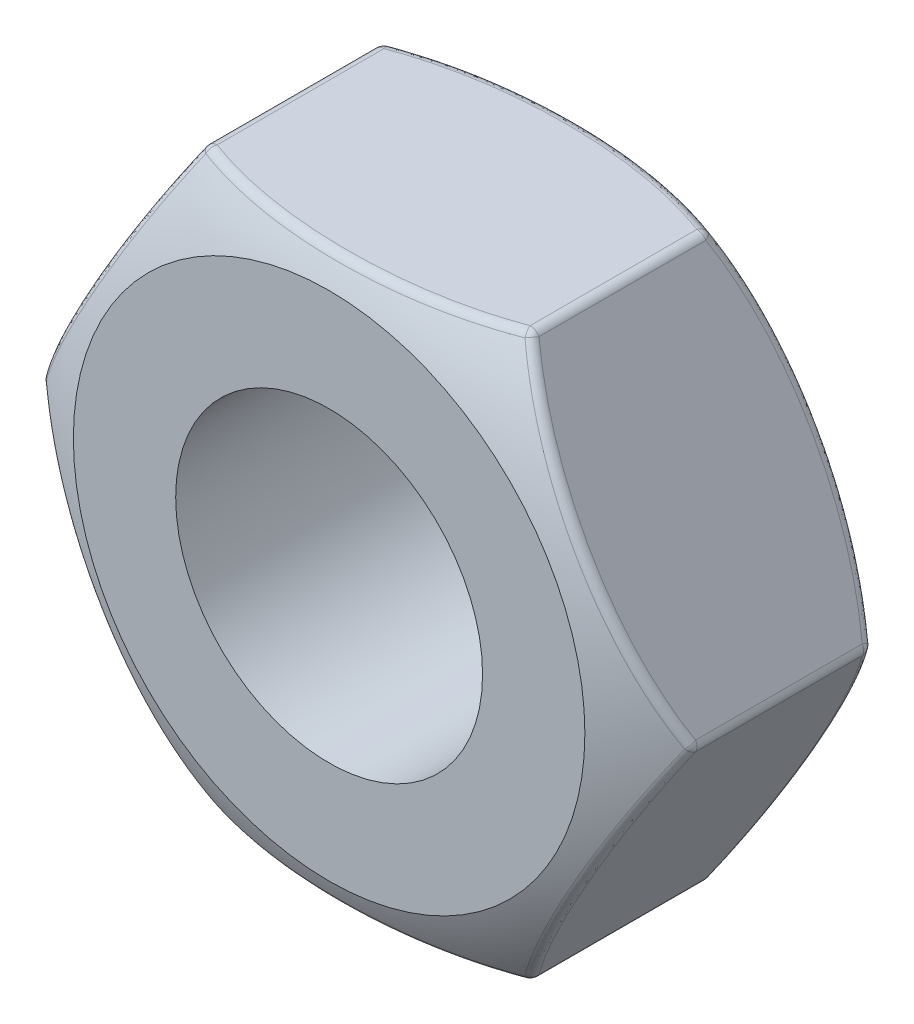
from build123d import *

# Parameters (mm, degrees)
EXTRUDE1_DEPTH     = 2.5
SKETCH3_R          = 1.5
CUT_EXTRUDE1_DEPTH = 12.5
FILLET1_R          = 0.1
FILLET2_R          = 0.1


with BuildPart() as part:
    # Sketch1 → Extrude1 (new body)
    with BuildSketch(Plane.XY):
        Polygon((3.175426481, 0), (1.58771324, 2.75), (-1.58771324, 2.75), (-3.175426481, 0), (-1.58771324, -2.75), (1.58771324, -2.75), align=None)
    extrude(amount=EXTRUDE1_DEPTH)

    # Sketch2 → Cut-Revolve1 (revolve, cut)
    with BuildSketch(Plane(origin=(0, 0, 0), x_dir=(0, 0, -1), z_dir=(1, 0, 0))):
        with BuildLine():
            Line((-0.5, 3.3), (0.473267316, 3.3))
            Line((0.473267316, 3.3), (0.473267316, 2.5))
            Line((0.473267316, 2.5), (0, 2.5))
            ThreePointArc((0, 2.5), (-0.218356598, 2.919777126), (-0.5, 3.3))
        make_face()
        with BuildLine():
            Line((-2, 3.3), (-2.836315201, 3.3))
            Line((-2.836315201, 3.3), (-2.836315201, 2.5))
            Line((-2.836315201, 2.5), (-2.5, 2.5))
            ThreePointArc((-2.5, 2.5), (-2.281643402, 2.919777126), (-2, 3.3))
        make_face()
    revolve(axis=Axis((0, 0, -1.011768521), (0, 0, 1)), mode=Mode.SUBTRACT)

    # Sketch3 → Cut-Extrude1 (cut)
    with BuildSketch(Plane.XY.offset(2.5)):
        Circle(SKETCH3_R)
    extrude(amount=-CUT_EXTRUDE1_DEPTH, mode=Mode.SUBTRACT)

    # Fillet1
    fillet1_edges = [part.edges().sort_by_distance(p)[0] for p in [
        (-1.58771324, 2.75, 1.25),
        (-3.175426481, 0, 1.25),
        (-1.58771324, -2.75, 1.25),
        (1.58771324, -2.75, 1.25),
        (3.175426481, 0, 1.25),
        (1.58771324, 2.75, 1.25),
    ]]
    fillet(fillet1_edges, radius=FILLET1_R)

    # Fillet2
    fillet2_edges = [part.edges().sort_by_distance(p)[0] for p in [
        (-2.381569862, 1.374999998, 2.380180613),
        (-2.381569862, 1.374999998, 0.119819387),
        (-2.381569859, -1.375000002, 0.119819387),
        (2.381569859, 1.375000002, 0.119819387),
        (2.381569862, -1.374999998, 0.119819387),
        (1.579978213, 2.73660254, 0.385282859),
        (3.159956427, 0, 0.385282859),
        (1.579978213, -2.73660254, 0.385282859),
        (-1.579978213, -2.73660254, 0.385282859),
        (-3.159956427, 0, 0.385282859),
        (-1.579978213, 2.73660254, 0.385282859),
        (2.381569859, 1.375000002, 2.380180613),
        (-2.381569859, -1.375000002, 2.380180613),
        (2.381569862, -1.374999998, 2.380180613),
        (1.579978213, 2.73660254, 2.114717141),
        (3.159956427, 0, 2.114717141),
        (1.579978213, -2.73660254, 2.114717141),
        (-1.579978213, -2.73660254, 2.114717141),
        (-3.159956427, 0, 2.114717141),
        (-1.579978213, 2.73660254, 2.114717141),
    ]]
    fillet(fillet2_edges, radius=FILLET2_R)


solid = part.part
